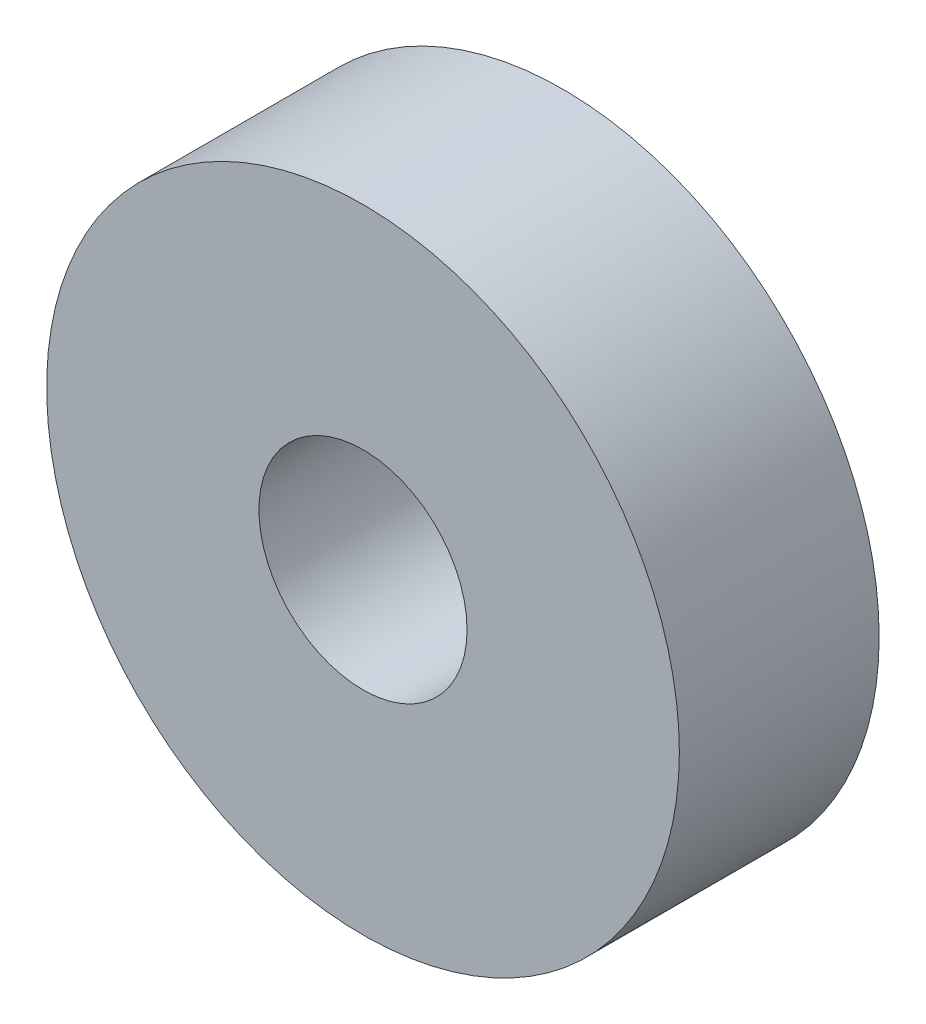
from build123d import *

# Parameters (mm, degrees)
SKETCH1_R           = 9.5
SKETCH1_R_2         = 3.125
BOSS_EXTRUDE1_DEPTH = 6


with BuildPart() as part:
    # Sketch1 → Boss-Extrude1 (new body)
    with BuildSketch(Plane.XY):
        Circle(SKETCH1_R)
        Circle(SKETCH1_R_2, mode=Mode.SUBTRACT)
    extrude(amount=BOSS_EXTRUDE1_DEPTH)


solid = part.part
